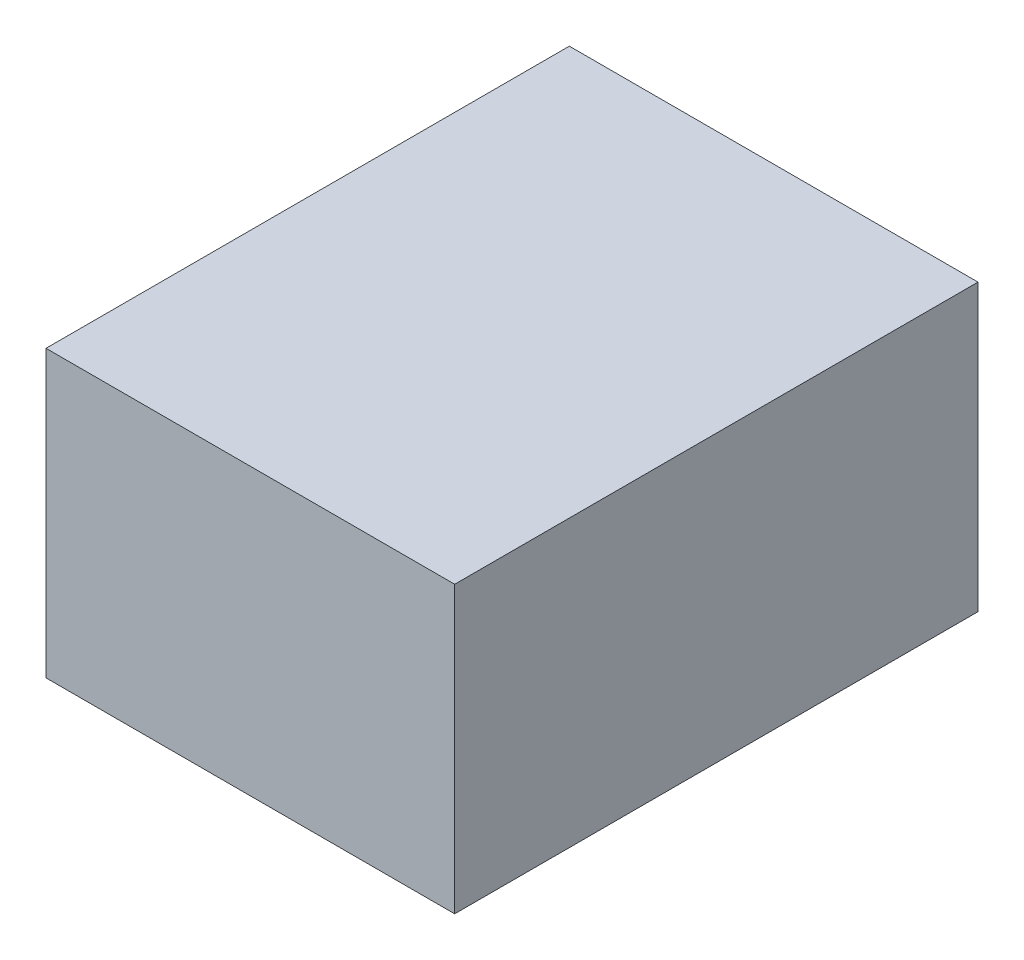
from build123d import *

# Parameters (mm, degrees)
SKETCH1_W           = 17.18
SKETCH1_H           = 12
BOSS_EXTRUDE1_DEPTH = 22


with BuildPart() as part:
    # Sketch1 → Boss-Extrude1 (new body)
    with BuildSketch(Plane.XY):
        with Locations((8.59, 6)):
            Rectangle(SKETCH1_W, SKETCH1_H)
    extrude(amount=BOSS_EXTRUDE1_DEPTH)


solid = part.part
